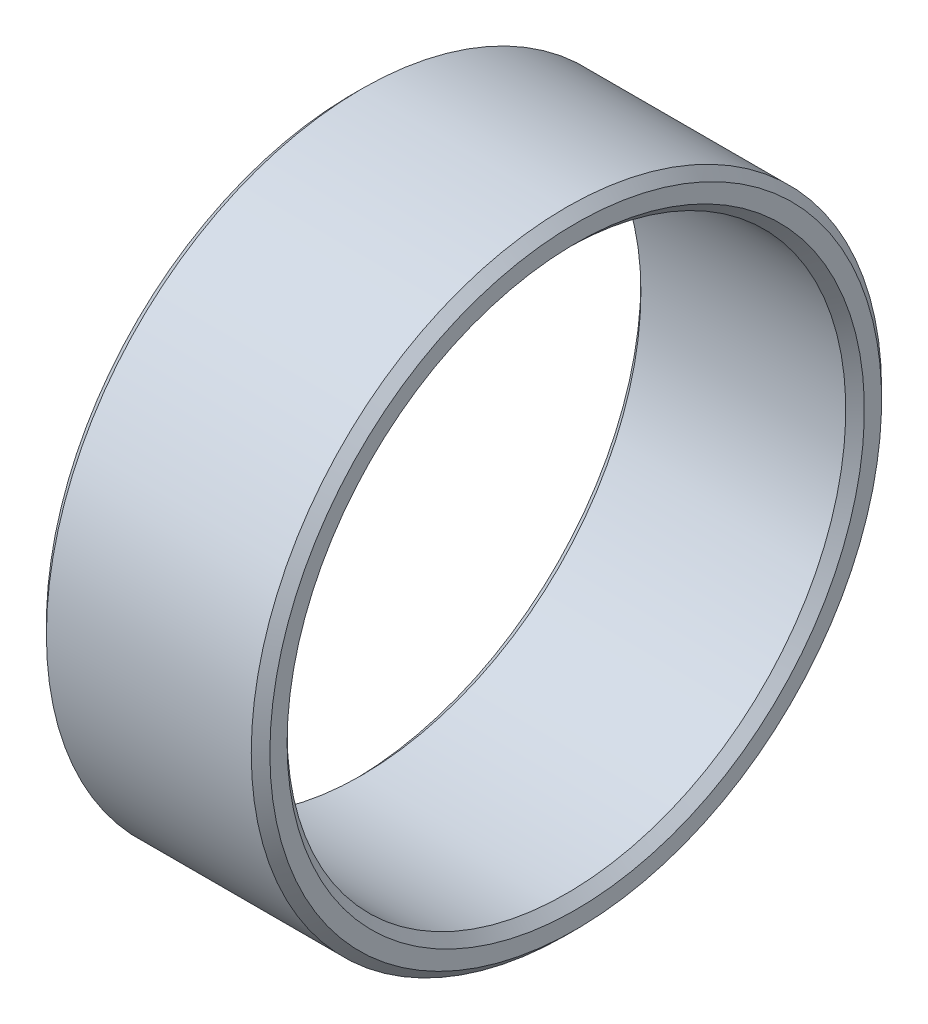
from build123d import *

# Parameters (mm, degrees)
SKETCH1_W     = 12
SKETCH1_H     = 1.925
CHAMFER1_SIZE = 0.5


with BuildPart() as part:
    # Sketch1 → Revolve1 (revolve)
    with BuildSketch(Plane.XY):
        with Locations((0, 15.9625)):
            Rectangle(SKETCH1_W, SKETCH1_H)
    revolve(axis=Axis((0, 0, 0), (1, 0, 0)))

    # Chamfer1
    chamfer1_edges = [part.edges().sort_by_distance(p)[0] for p in [
        (-6, -16.925, 0),
        (6, -16.925, 0),
        (6, -15, 0),
        (-6, -15, 0),
    ]]
    chamfer(chamfer1_edges, length=CHAMFER1_SIZE)


solid = part.part
